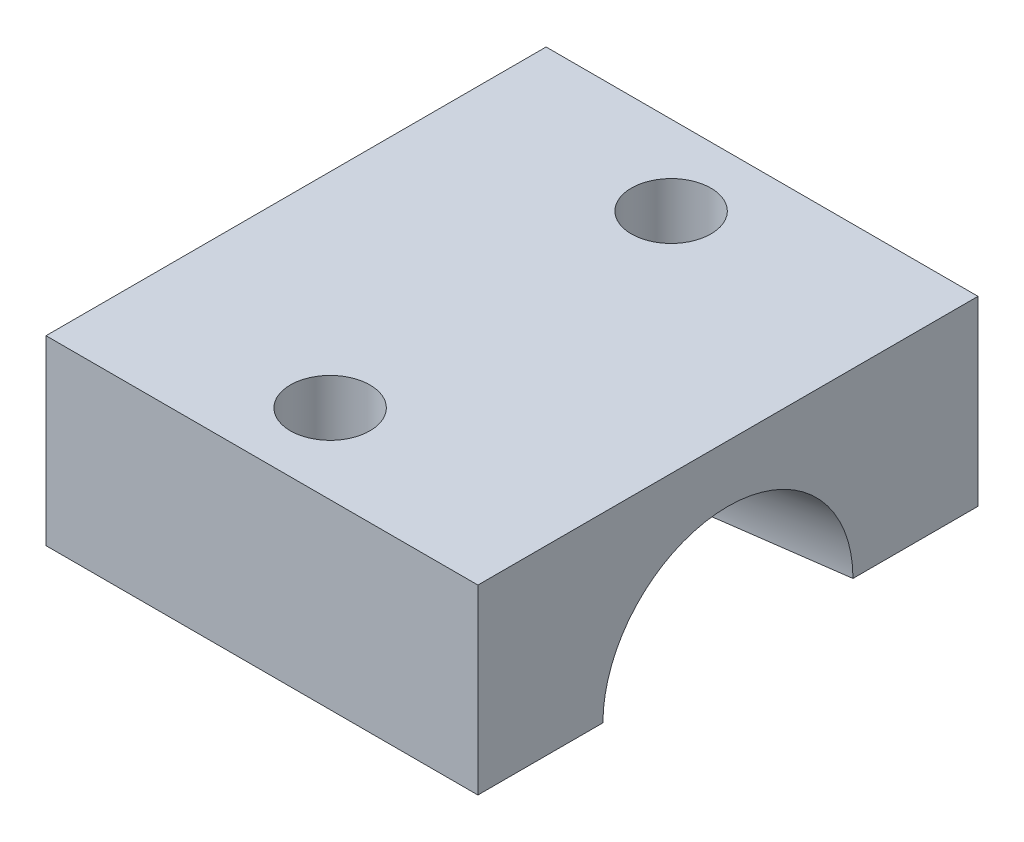
from build123d import *

# Parameters (mm, degrees)
SKETCH_1_W          = 17
SKETCH_1_H          = 22
SKETCH_1_R          = 1.75
EXTRUDE_1_DEPTH     = 4
SKETCH_2_R          = 3.5
CUT_EXTRUDE_1_DEPTH = 2.5
SKETCH_4_R          = 5.5
SKETCH_3_R          = 3.5
EXTRUDE_2_DEPTH     = 2


with BuildPart() as part:
    # 草圖1 → 填料-伸長1 (new body, symmetric)
    with BuildSketch(Plane(origin=(0, 0, 0), x_dir=(1, 0, 0), z_dir=(0, 1, 0))):
        Rectangle(SKETCH_1_W, SKETCH_1_H)
        with Locations((-1.5, 7.5)):
            Circle(SKETCH_1_R, mode=Mode.SUBTRACT)
        with Locations((-1.5, -7.5)):
            Circle(SKETCH_1_R, mode=Mode.SUBTRACT)
    extrude(amount=EXTRUDE_1_DEPTH, both=True)

    # 草圖2 → 除料-伸長1 (cut)
    with BuildSketch(Plane.ZY.offset(8.5)):
        with Locations((0, -4)):
            Circle(SKETCH_2_R)
    extrude(amount=-CUT_EXTRUDE_1_DEPTH, mode=Mode.SUBTRACT)

    # 草圖4 → 除料-疊層拉伸1 section 0
    with BuildSketch(Plane(origin=(8.5, 0, 0), x_dir=(0, 0, -1), z_dir=(1, 0, 0))):
        with Locations((0, -4)):
            Circle(SKETCH_4_R)
    # 草圖3 → 除料-疊層拉伸1 section 1
    with BuildSketch(Plane.ZY.offset(6)):
        with Locations((0, -4)):
            Circle(SKETCH_3_R)
    loft(mode=Mode.SUBTRACT)

    # 草圖5 → 填料-伸長2 (add)
    with BuildSketch(Plane.ZY.offset(8.5)):
        with BuildLine():
            Line((3.5, -4), (11, -4))
            Line((11, -4), (11, 4))
            Line((11, 4), (-11, 4))
            Line((-11, 4), (-11, -4))
            Line((-11, -4), (-3.5, -4))
            ThreePointArc((-3.5, -4), (0, -0.5), (3.5, -4))
        make_face()
    extrude(amount=EXTRUDE_2_DEPTH)


solid = part.part
